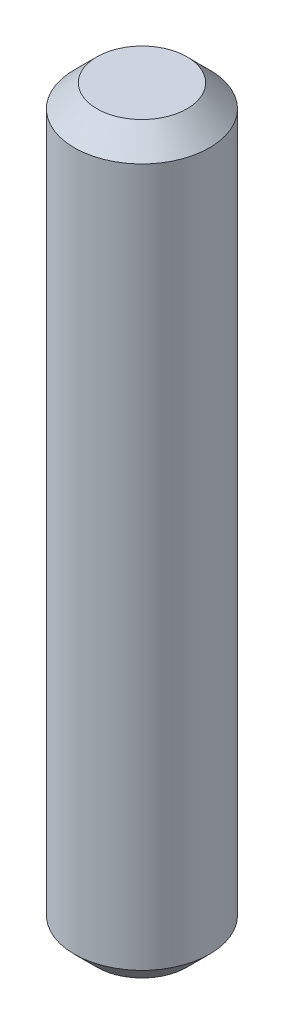
from build123d import *

# Parameters (mm, degrees)
SZKIC1_R                    = 3
DODANIE_WYCI_GNI_CIE1_DEPTH = 33
SFAZOWANIE1_SIZE            = 1


with BuildPart() as part:
    # Szkic1 → Dodanie-wyciągnięcie1 (new body)
    with BuildSketch(Plane(origin=(0, 0, 0), x_dir=(1, 0, 0), z_dir=(0, 1, 0))):
        Circle(SZKIC1_R)
    extrude(amount=DODANIE_WYCI_GNI_CIE1_DEPTH)

    # Sfazowanie1
    sfazowanie1_edges = [part.edges().sort_by_distance(p)[0] for p in [
        (-3, 0, 0),
        (-3, 33, 0),
    ]]
    chamfer(sfazowanie1_edges, length=SFAZOWANIE1_SIZE)


solid = part.part
